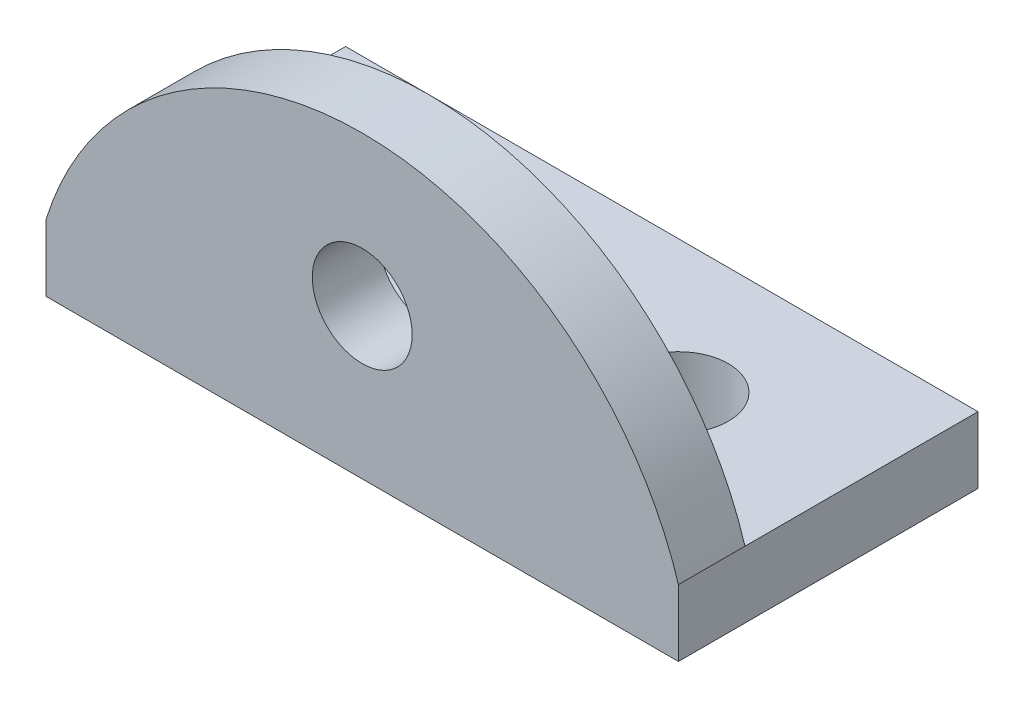
from build123d import *

# Parameters (mm, degrees)
SKETCH1_W           = 19
SKETCH1_H           = 9
BOSS_EXTRUDE1_DEPTH = 2
BOSS_EXTRUDE2_DEPTH = 2
SKETCH4_R           = 1.5
CUT_EXTRUDE1_DEPTH  = 2
SKETCH5_R           = 1.5
CUT_EXTRUDE2_DEPTH  = 2


with BuildPart() as part:
    # Sketch1 → Boss-Extrude1 (new body)
    with BuildSketch(Plane(origin=(0, 0, 0), x_dir=(1, 0, 0), z_dir=(0, 1, 0))):
        with Locations((9.5, 4.5)):
            Rectangle(SKETCH1_W, SKETCH1_H)
    extrude(amount=BOSS_EXTRUDE1_DEPTH)

    # Sketch3 → Boss-Extrude2 (add)
    with BuildSketch(Plane.XY):
        with BuildLine():
            Line((0, 2), (19, 2))
            ThreePointArc((19, 2), (9.5, 9), (0, 2))
        make_face()
    extrude(amount=-BOSS_EXTRUDE2_DEPTH)

    # Sketch4 → Cut-Extrude1 (cut)
    with BuildSketch(Plane(origin=(0, 2, 0), x_dir=(1, 0, 0), z_dir=(0, 1, 0))):
        with Locations((5, 5)):
            Circle(SKETCH4_R)
        with Locations((14, 5)):
            Circle(SKETCH4_R)
    extrude(amount=-CUT_EXTRUDE1_DEPTH, mode=Mode.SUBTRACT)

    # Sketch5 → Cut-Extrude2 (cut)
    with BuildSketch(Plane.XY):
        with Locations((9.5, 4.5)):
            Circle(SKETCH5_R)
    extrude(amount=-CUT_EXTRUDE2_DEPTH, mode=Mode.SUBTRACT)


solid = part.part
